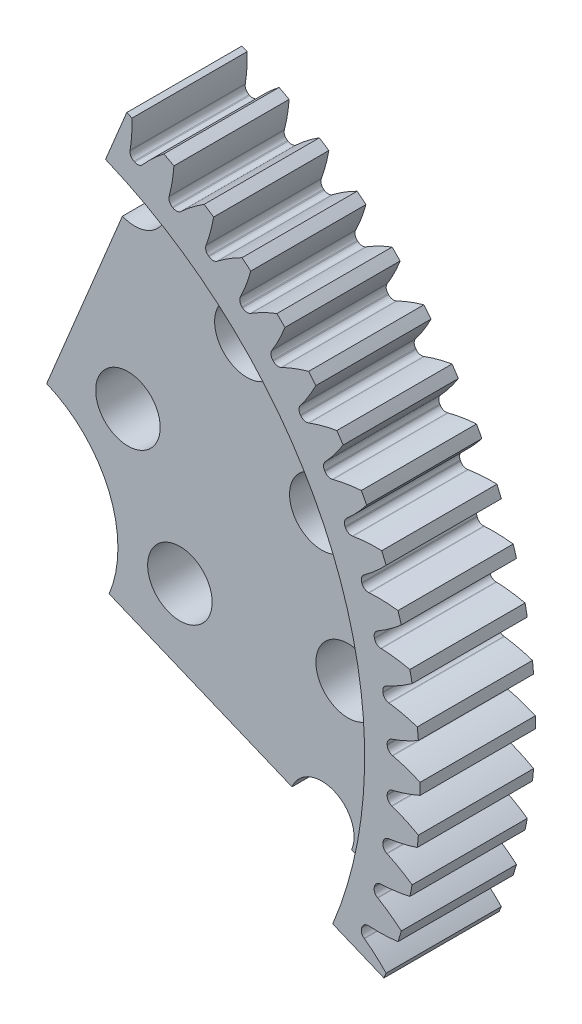
from build123d import *

# Parameters (mm, degrees)
SKETCH_1_W                = 26.19375
SKETCH_1_H                = 6.35
REVOLVE_1_ANGLE           = 90
CUT_EXTRUDE_1_DEPTH       = 7.35
CUT_EXTRUDE_2_DEPTH       = 7.35
CUT_EXTRUDE_3_DEPTH       = 7.35
CUT_EXTRUDE_4_DEPTH       = 7.35
CUT_EXTRUDE_5_DEPTH       = 7.35
CUT_EXTRUDE_6_DEPTH       = 7.35
CUT_EXTRUDE_7_DEPTH       = 7.35
CUT_EXTRUDE_8_DEPTH       = 7.35
CUT_EXTRUDE_9_DEPTH       = 7.35
CUT_EXTRUDE_10_DEPTH      = 7.35
CUT_EXTRUDE_11_DEPTH      = 7.35
CUT_EXTRUDE_12_DEPTH      = 7.35
CUT_EXTRUDE_13_DEPTH      = 7.35
CUT_EXTRUDE_14_DEPTH      = 7.35
CUT_EXTRUDE_15_DEPTH      = 7.35
CUT_EXTRUDE_16_DEPTH      = 7.35
HOLE_WIZARD_1_D           = 12.7254
HOLE_WIZARD_1_DEPTH       = 6.35
HOLE_WIZARD_1_CBORE_D     = 46.275625
HOLE_WIZARD_1_CBORE_DEPTH = 3.175
HOLE_WIZARD_M3_1_D        = 3.556
HOLE_WIZARD_M3_1_DEPTH    = 3.175
HOLE_WIZARD_M3_2_D        = 3.556
HOLE_WIZARD_M3_2_DEPTH    = 6.35
FILLET_1_R                = 0.371048086


with BuildPart() as part:
    # 草图1 → 旋转1 (revolve)
    with BuildSketch(Plane(origin=(0, 0, 0), x_dir=(0.923879533, -0.382683432, 0), z_dir=(-0.382683432, -0.923879533, 0))):
        with Locations((13.096875, 3.175)):
            Rectangle(SKETCH_1_W, SKETCH_1_H)
    revolve(axis=Axis((0, 0, 6.35), (0, 0, 1)), revolution_arc=REVOLVE_1_ANGLE)

    # 草图2 → 切除-拉伸1 (cut, through all)
    with BuildSketch(Plane(origin=(0, 0, 0), x_dir=(-1, 0, 0), z_dir=(0, 0, -1))):
        with BuildLine():
            Line((-23.125108614, -8.68641351), (-22.87890536, -8.502764289))
            ThreePointArc((-22.87890536, -8.502764289), (-22.981031003, -8.222744375), (-23.079729567, -7.941498231))
            Line((-23.079729567, -7.941498231), (-23.386553087, -7.955725155))
            ThreePointArc((-23.386553087, -7.955725155), (-24.181098072, -7.966122615), (-24.973177408, -7.902717835))
            ThreePointArc((-24.973177408, -7.902717835), (-24.662569857, -8.824408597), (-24.317958312, -9.733932535))
            ThreePointArc((-24.317958312, -9.733932535), (-23.745675498, -9.18268157), (-23.125108614, -8.68641351))
        make_face()
    extrude(amount=-CUT_EXTRUDE_1_DEPTH, mode=Mode.SUBTRACT)

    # 草图3 → 切除-拉伸2 (cut, through all)
    with BuildSketch(Plane(origin=(0, 0, 0), x_dir=(-1, 0, 0), z_dir=(0, 0, -1))):
        with BuildLine():
            Line((-23.865172307, -6.377929039), (-23.602153818, -6.219296278))
            ThreePointArc((-23.602153818, -6.219296278), (-23.676340947, -5.930614672), (-23.746997307, -5.641048655))
            Line((-23.746997307, -5.641048655), (-24.053737871, -5.625133108))
            ThreePointArc((-24.053737871, -5.625133108), (-24.845476034, -5.557601474), (-25.627526536, -5.416864655))
            ThreePointArc((-25.627526536, -5.416864655), (-25.408756138, -6.364562087), (-25.154952927, -7.303484257))
            ThreePointArc((-25.154952927, -7.303484257), (-24.531393768, -6.810981241), (-23.865172307, -6.377929039))
        make_face()
    extrude(amount=-CUT_EXTRUDE_2_DEPTH, mode=Mode.SUBTRACT)

    # 草图4 → 切除-拉伸3 (cut, through all)
    with BuildSketch(Plane(origin=(0, 0, 0), x_dir=(-1, 0, 0), z_dir=(0, 0, -1))):
        with BuildLine():
            Line((-24.375401345, -4.008021624), (-24.098100632, -3.875933044))
            ThreePointArc((-24.098100632, -3.875933044), (-24.143634785, -3.581369909), (-24.185568482, -3.286272696))
            Line((-24.185568482, -3.286272696), (-24.48927201, -3.240367954))
            ThreePointArc((-24.48927201, -3.240367954), (-25.27057848, -3.095557593), (-26.035068574, -2.878844106))
            ThreePointArc((-26.035068574, -2.878844106), (-25.910242208, -3.843421365), (-25.749691595, -4.802699433))
            ThreePointArc((-25.749691595, -4.802699433), (-25.080861306, -4.373687439), (-24.375401345, -4.008021624))
        make_face()
    extrude(amount=-CUT_EXTRUDE_3_DEPTH, mode=Mode.SUBTRACT)

    # 草图5 → 切除-拉伸4 (cut, through all)
    with BuildSketch(Plane(origin=(0, 0, 0), x_dir=(-1, 0, 0), z_dir=(0, 0, -1))):
        with BuildLine():
            Line((-24.650881943, -1.59951477), (-24.361969564, -1.495242455))
            ThreePointArc((-24.361969564, -1.495242455), (-24.378412221, -1.197634595), (-24.391219411, -0.899848135))
            Line((-24.391219411, -0.899848135), (-24.688961072, -0.824396285))
            ThreePointArc((-24.688961072, -0.824396285), (-25.45231144, -0.6037018), (-26.19187867, -0.313098715))
            ThreePointArc((-26.19187867, -0.313098715), (-26.162198481, -1.285266394), (-26.096446656, -2.255661988))
            ThreePointArc((-26.096446656, -2.255661988), (-25.388786439, -1.894272637), (-24.650881943, -1.59951477))
        make_face()
    extrude(amount=-CUT_EXTRUDE_4_DEPTH, mode=Mode.SUBTRACT)

    # 草图6 → 切除-拉伸5 (cut, through all)
    with BuildSketch(Plane(origin=(0, 0, 0), x_dir=(-1, 0, 0), z_dir=(0, 0, -1))):
        with BuildLine():
            Line((-24.688961072, 0.824396285), (-24.391219411, 0.899848135))
            ThreePointArc((-24.391219411, 0.899848135), (-24.378412221, 1.197634595), (-24.361969564, 1.495242455))
            Line((-24.361969564, 1.495242455), (-24.650881942, 1.59951477))
            ThreePointArc((-24.650881942, 1.59951477), (-25.388924728, 1.893967972), (-26.096446656, 2.255661988))
            ThreePointArc((-26.096446656, 2.255661988), (-26.162198481, 1.285266394), (-26.19187867, 0.313098715))
            ThreePointArc((-26.19187867, 0.313098715), (-25.45220368, 0.603385047), (-24.688961072, 0.824396285))
        make_face()
    extrude(amount=-CUT_EXTRUDE_5_DEPTH, mode=Mode.SUBTRACT)

    # 草图7 → 切除-拉伸6 (cut, through all)
    with BuildSketch(Plane(origin=(0, 0, 0), x_dir=(-1, 0, 0), z_dir=(0, 0, -1))):
        with BuildLine():
            Line((-24.48927201, 3.240367954), (-24.185568482, 3.286272696))
            ThreePointArc((-24.185568482, 3.286272696), (-24.143634785, 3.581369909), (-24.098100632, 3.875933044))
            Line((-24.098100632, 3.875933044), (-24.375401344, 4.008021624))
            ThreePointArc((-24.375401344, 4.008021624), (-25.081028791, 4.373397796), (-25.749691595, 4.802699433))
            ThreePointArc((-25.749691595, 4.802699433), (-25.910242208, 3.843421365), (-26.035068574, 2.878844106))
            ThreePointArc((-26.035068574, 2.878844106), (-25.270502286, 3.095231803), (-24.48927201, 3.240367954))
        make_face()
    extrude(amount=-CUT_EXTRUDE_6_DEPTH, mode=Mode.SUBTRACT)

    # 草图8 → 切除-拉伸7 (cut, through all)
    with BuildSketch(Plane(origin=(0, 0, 0), x_dir=(-1, 0, 0), z_dir=(0, 0, -1))):
        with BuildLine():
            Line((-24.053737872, 5.625133108), (-23.746997307, 5.641048655))
            ThreePointArc((-23.746997307, 5.641048655), (-23.676340947, 5.930614672), (-23.602153818, 6.219296278))
            Line((-23.602153818, 6.219296278), (-23.865172307, 6.377929038))
            ThreePointArc((-23.865172307, 6.377929038), (-24.531588837, 6.810709409), (-25.154952927, 7.303484257))
            ThreePointArc((-25.154952927, 7.303484257), (-25.408756138, 6.364562087), (-25.627526536, 5.416864655))
            ThreePointArc((-25.627526536, 5.416864655), (-24.84543214, 5.557269785), (-24.053737872, 5.625133108))
        make_face()
    extrude(amount=-CUT_EXTRUDE_7_DEPTH, mode=Mode.SUBTRACT)

    # 草图9 → 切除-拉伸8 (cut, through all)
    with BuildSketch(Plane(origin=(0, 0, 0), x_dir=(-1, 0, 0), z_dir=(0, 0, -1))):
        with BuildLine():
            Line((-23.386553088, 7.955725155), (-23.079729567, 7.941498231))
            ThreePointArc((-23.079729567, 7.941498231), (-22.981031003, 8.222744375), (-22.87890536, 8.502764289))
            Line((-22.87890536, 8.502764289), (-23.125108613, 8.68641351))
            ThreePointArc((-23.125108613, 8.68641351), (-23.745896271, 9.182430167), (-24.317958312, 9.733932535))
            ThreePointArc((-24.317958312, 9.733932535), (-24.662569857, 8.824408597), (-24.973177408, 7.902717835))
            ThreePointArc((-24.973177408, 7.902717835), (-24.181086901, 7.96578822), (-23.386553088, 7.955725155))
        make_face()
    extrude(amount=-CUT_EXTRUDE_8_DEPTH, mode=Mode.SUBTRACT)

    # 草图10 → 切除-拉伸9 (cut, through all)
    with BuildSketch(Plane(origin=(0, 0, 0), x_dir=(-1, 0, 0), z_dir=(0, 0, -1))):
        with BuildLine():
            Line((-22.494143013, 10.209699219), (-22.190191414, 10.165466838))
            ThreePointArc((-22.190191414, 10.165466838), (-22.064401169, 10.435684554), (-21.935320537, 10.704346033))
            Line((-21.935320537, 10.704346033), (-22.162337483, 10.911243071))
            ThreePointArc((-22.162337483, 10.911243071), (-22.731517744, 11.465719103), (-23.246768465, 12.070637722))
            ThreePointArc((-23.246768465, 12.070637722), (-23.678869547, 11.199271229), (-24.07832293, 10.312463524))
            ThreePointArc((-24.07832293, 10.312463524), (-23.283864576, 10.297591761), (-22.494143013, 10.209699219))
        make_face()
    extrude(amount=-CUT_EXTRUDE_9_DEPTH, mode=Mode.SUBTRACT)

    # 草图11 → 切除-拉伸10 (cut, through all)
    with BuildSketch(Plane(origin=(0, 0, 0), x_dir=(-1, 0, 0), z_dir=(0, 0, -1))):
        with BuildLine():
            Line((-21.385102045, 12.365348299), (-21.086949588, 12.291536443))
            ThreePointArc((-21.086949588, 12.291536443), (-20.935279089, 12.548123386), (-20.780486586, 12.802839072))
            Line((-20.780486586, 12.802839072), (-20.986130927, 13.030991396))
            ThreePointArc((-20.986130927, 13.030991396), (-21.498222275, 13.638586896), (-21.951699529, 14.291096069))
            ThreePointArc((-21.951699529, 14.291096069), (-22.467128778, 13.466278756), (-22.95158104, 12.622894551))
            ThreePointArc((-22.95158104, 12.622894551), (-22.162405907, 12.530223863), (-21.385102045, 12.365348299))
        make_face()
    extrude(amount=-CUT_EXTRUDE_10_DEPTH, mode=Mode.SUBTRACT)

    # 草图12 → 切除-拉伸11 (cut, through all)
    with BuildSketch(Plane(origin=(0, 0, 0), x_dir=(-1, 0, 0), z_dir=(0, 0, -1))):
        with BuildLine():
            Line((-20.070110854, 14.401912315), (-19.780628909, 14.299231832))
            ThreePointArc((-19.780628909, 14.299231832), (-19.604538827, 14.53971693), (-19.425525189, 14.778033772))
            Line((-19.425525189, 14.778033772), (-19.607816459, 15.025244151))
            ThreePointArc((-19.607816459, 15.025244151), (-20.057887173, 15.680107642), (-20.445223727, 16.373923348))
            ThreePointArc((-20.445223727, 16.373923348), (-21.039017278, 15.603598657), (-21.603802877, 14.811760203))
            ThreePointArc((-21.603802877, 14.811760203), (-20.827511155, 14.64218306), (-20.070110854, 14.401912315))
        make_face()
    extrude(amount=-CUT_EXTRUDE_11_DEPTH, mode=Mode.SUBTRACT)

    # 草图13 → 切除-拉伸12 (cut, through all)
    with BuildSketch(Plane(origin=(0, 0, 0), x_dir=(-1, 0, 0), z_dir=(0, 0, -1))):
        with BuildLine():
            Line((-18.561833524, 16.299778043), (-18.283809961, 16.169217802))
            ThreePointArc((-18.283809961, 16.169217802), (-18.084996139, 16.391285053), (-17.883485365, 16.610907929))
            Line((-17.883485365, 16.610907929), (-18.040667998, 16.874795591))
            ThreePointArc((-18.040667998, 16.874795591), (-18.424383653, 17.57062038), (-18.741849244, 18.299060795))
            ThreePointArc((-18.741849244, 18.299060795), (-19.40828854, 17.590647373), (-20.047968283, 16.857980507))
            ThreePointArc((-20.047968283, 16.857980507), (-19.292036084, 16.61313003), (-18.561833524, 16.299778043))
        make_face()
    extrude(amount=-CUT_EXTRUDE_12_DEPTH, mode=Mode.SUBTRACT)

    # 草图14 → 切除-拉伸13 (cut, through all)
    with BuildSketch(Plane(origin=(0, 0, 0), x_dir=(-1, 0, 0), z_dir=(0, 0, -1))):
        with BuildLine():
            Line((-16.874795591, 18.040667998), (-16.610907929, 17.883485365))
            ThreePointArc((-16.610907929, 17.883485365), (-16.391285053, 18.084996139), (-16.169217802, 18.283809961))
            Line((-16.169217802, 18.283809961), (-16.299778044, 18.561833525))
            ThreePointArc((-16.299778044, 18.561833525), (-16.613443246, 19.291918438), (-16.857980507, 20.047968283))
            ThreePointArc((-16.857980507, 20.047968283), (-17.590647373, 19.40828854), (-18.299060795, 18.741849244))
            ThreePointArc((-18.299060795, 18.741849244), (-17.57076816, 18.424083477), (-16.874795591, 18.040667998))
        make_face()
    extrude(amount=-CUT_EXTRUDE_13_DEPTH, mode=Mode.SUBTRACT)

    # 草图15 → 切除-拉伸14 (cut, through all)
    with BuildSketch(Plane(origin=(0, 0, 0), x_dir=(-1, 0, 0), z_dir=(0, 0, -1))):
        with BuildLine():
            Line((-15.025244151, 19.607816458), (-14.778033772, 19.425525189))
            ThreePointArc((-14.778033772, 19.425525189), (-14.53971693, 19.604538827), (-14.299231832, 19.780628909))
            Line((-14.299231832, 19.780628909), (-14.401912316, 20.070110855))
            ThreePointArc((-14.401912316, 20.070110855), (-14.642506299, 20.827424776), (-14.811760203, 21.603802877))
            ThreePointArc((-14.811760203, 21.603802877), (-15.603598657, 21.039017278), (-16.373923348, 20.445223727))
            ThreePointArc((-16.373923348, 20.445223727), (-15.680284133, 20.057602927), (-15.025244151, 19.607816458))
        make_face()
    extrude(amount=-CUT_EXTRUDE_14_DEPTH, mode=Mode.SUBTRACT)

    # 草图16 → 切除-拉伸15 (cut, through all)
    with BuildSketch(Plane(origin=(0, 0, 0), x_dir=(-1, 0, 0), z_dir=(0, 0, -1))):
        with BuildLine():
            Line((-13.030991396, 20.986130927), (-12.802839072, 20.780486586))
            ThreePointArc((-12.802839072, 20.780486586), (-12.548123386, 20.935279089), (-12.291536443, 21.086949588))
            Line((-12.291536443, 21.086949588), (-12.365348299, 21.385102046))
            ThreePointArc((-12.365348299, 21.385102046), (-12.530554012, 22.162351628), (-12.622894551, 22.95158104))
            ThreePointArc((-12.622894551, 22.95158104), (-13.466278756, 22.467128778), (-14.291096069, 21.951699529))
            ThreePointArc((-14.291096069, 21.951699529), (-13.638790398, 21.497956697), (-13.030991396, 20.986130927))
        make_face()
    extrude(amount=-CUT_EXTRUDE_15_DEPTH, mode=Mode.SUBTRACT)

    # 草图17 → 切除-拉伸16 (cut, through all)
    with BuildSketch(Plane(origin=(0, 0, 0), x_dir=(-1, 0, 0), z_dir=(0, 0, -1))):
        with BuildLine():
            Line((-10.911243071, 22.162337483), (-10.704346033, 21.935320537))
            ThreePointArc((-10.704346033, 21.935320537), (-10.435684554, 22.064401169), (-10.165466838, 22.190191414))
            Line((-10.165466838, 22.190191414), (-10.209699219, 22.494143014))
            ThreePointArc((-10.209699219, 22.494143014), (-10.29792564, 23.283842918), (-10.312463524, 24.07832293))
            ThreePointArc((-10.312463524, 24.07832293), (-11.199271229, 23.678869547), (-12.070637722, 23.246768465))
            ThreePointArc((-12.070637722, 23.246768465), (-11.465947656, 22.731273392), (-10.911243071, 22.162337483))
        make_face()
    extrude(amount=-CUT_EXTRUDE_16_DEPTH, mode=Mode.SUBTRACT)

    # 孔1
    with Locations(Plane.XY.offset(6.35)):
        with Locations((0, 0)):
            CounterBoreHole(HOLE_WIZARD_1_D / 2, HOLE_WIZARD_1_CBORE_D / 2, HOLE_WIZARD_1_CBORE_DEPTH, depth=HOLE_WIZARD_1_DEPTH)

    # M3 间隙孔1
    with Locations(Plane.XY.offset(3.175)):
        with Locations((7.290119387, 17.599905094), (13.470384182, 13.470384182), (17.599905094, 7.290119387), (19.05, 0), (6.914797213, 6.914797213), (9.779, 0)):
            Hole(HOLE_WIZARD_M3_1_D / 2, depth=HOLE_WIZARD_M3_1_DEPTH)

    # M3 间隙孔2
    with Locations(Plane(origin=(0, 0, 0), x_dir=(-1, 0, 0), z_dir=(0, 0, -1))):
        with Locations((-17.599905094, -7.290119387)):
            Hole(HOLE_WIZARD_M3_2_D / 2, depth=HOLE_WIZARD_M3_2_DEPTH)

    # 圆角1
    fillet_1_edges = [part.edges().sort_by_distance(p)[0] for p in [
        (24.361969564, 1.495242455, 3.175),
        (24.391219411, 0.899848135, 3.175),
        (24.098100632, 3.875933044, 3.175),
        (24.185568482, 3.286272696, 3.175),
        (23.602153818, 6.219296278, 3.175),
        (23.746997307, 5.641048655, 3.175),
        (22.87890536, 8.502764289, 3.175),
        (23.079729567, 7.941498231, 3.175),
        (23.079729567, -7.941498231, 3.175),
        (22.87890536, -8.502764289, 3.175),
        (21.935320537, 10.704346033, 3.175),
        (22.190191414, 10.165466838, 3.175),
        (20.780486586, 12.802839072, 3.175),
        (21.086949588, 12.291536443, 3.175),
        (19.425525189, 14.778033772, 3.175),
        (19.780628909, 14.299231832, 3.175),
        (17.883485365, 16.610907929, 3.175),
        (18.283809961, 16.169217802, 3.175),
        (16.169217802, 18.283809961, 3.175),
        (16.610907929, 17.883485365, 3.175),
        (14.299231832, 19.780628909, 3.175),
        (14.778033772, 19.425525189, 3.175),
        (12.291536443, 21.086949588, 3.175),
        (12.802839072, 20.780486586, 3.175),
        (10.165466838, 22.190191414, 3.175),
        (10.704346033, 21.935320537, 3.175),
        (23.746997307, -5.641048655, 3.175),
        (23.602153818, -6.219296278, 3.175),
        (24.185568482, -3.286272696, 3.175),
        (24.098100632, -3.875933044, 3.175),
        (24.391219411, -0.899848135, 3.175),
        (24.361969564, -1.495242455, 3.175),
    ]]
    fillet(fillet_1_edges, radius=FILLET_1_R)


solid = part.part
